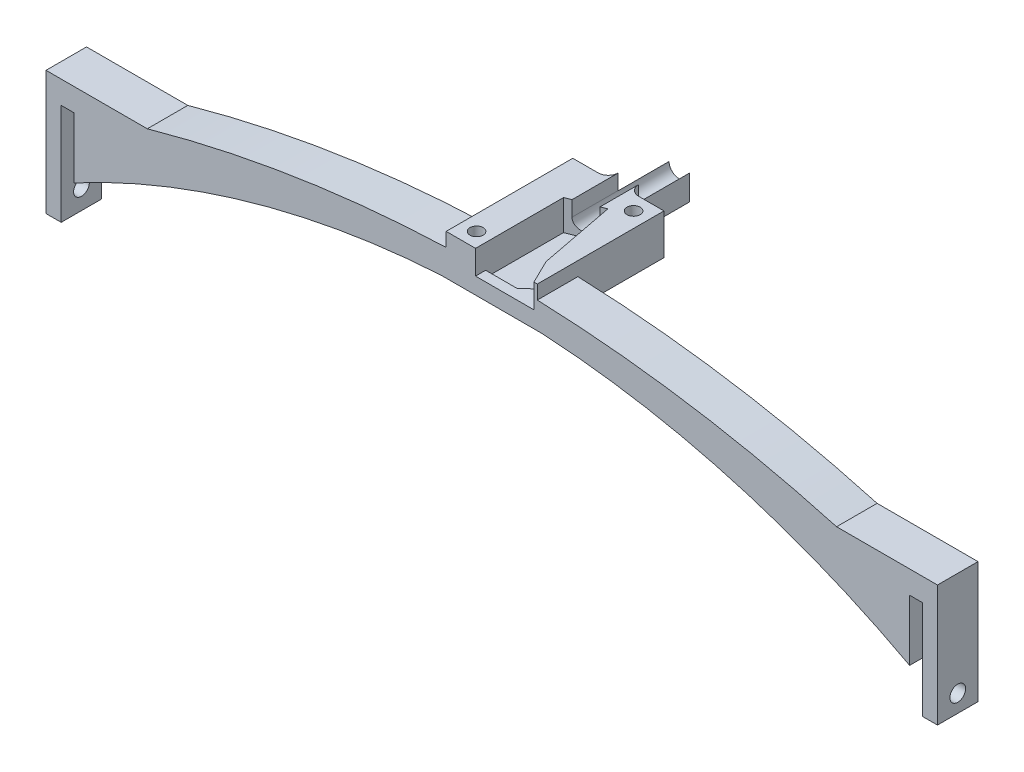
from build123d import *

# Parameters (mm, degrees)
BOSS_EXTRUDE1_DEPTH     = 8
SKETCH2_R               = 1.55
CUT_EXTRUDE1_DEPTH      = 177
BOSS_EXTRUDE3_START     = 20.459902
SKETCH3_R               = 1.3
BOSS_EXTRUDE3_DEPTH     = 8
CUT_EXTRUDE2_START      = -2
CUT_EXTRUDE2_DEPTH      = 40
SKETCH3_3_R             = 1.3
CUT_EXTRUDE3_DEPTH      = 29.4599021
CUT_EXTRUDE3_DEPTH_BACK = 9
CUT_EXTRUDE4_DEPTH      = 6
CUT_EXTRUDE5_DEPTH      = 4.75
FILLET1_R               = 2


with BuildPart() as part:
    # Sketch1 → Boss-Extrude1 (new body)
    with BuildSketch(Plane.XY):
        with BuildLine():
            Line((-3, 0), (-3, 16.5))
            Line((-3, 16.5), (17, 16.5))
            ThreePointArc((17, 16.5), (85.039654136, 25.877266165), (153.079308271, 16.5))
            Line((153.079308271, 16.5), (173, 16.5))
            Line((173, 16.5), (173, 0.544153422))
            Line((173, 0.544153422), (173, -7.455846578))
            Line((173, -7.455846578), (170, -7.455846578))
            Line((170, -7.455846578), (170, 0))
            Line((170, 0), (170.005951762, 12.036791894))
            Line((170.005951762, 12.036791894), (170, 12))
            Line((170, 12), (167.5, 12))
            Line((167.5, 12), (167.5, 0))
            ThreePointArc((167.5, 0), (132.367862473, 14.191115036), (95, 20.459901787))
            Line((95, 20.459901787), (75, 20.459901787))
            ThreePointArc((75, 20.459901787), (37.632137527, 14.191115036), (2.5, 0))
            Line((2.5, 0), (2.5, 12))
            Line((2.5, 12), (0, 12))
            Line((0, 12), (0, 0))
            Line((0, 0), (0, -8))
            Line((0, -8), (-3, -8))
            Line((-3, -8), (-3, 0))
        make_face()
    extrude(amount=BOSS_EXTRUDE1_DEPTH)

    # Sketch2 → Cut-Extrude1 (cut, through all)
    with BuildSketch(Plane.ZY.offset(3)):
        with Locations((4, -4)):
            Circle(SKETCH2_R)
    extrude(amount=-CUT_EXTRUDE1_DEPTH, mode=Mode.SUBTRACT)

    # Sketch3 → Boss-Extrude3 (add)
    with BuildSketch(Plane(origin=(0, 0, 0), x_dir=(1, 0, 0), z_dir=(0, 1, 0)).offset(BOSS_EXTRUDE3_START)):
        Polygon((94, 17), (87, 17), (87, 29), (83, 29), (83, 17), (76, 17), (76, -8), (94, -8), align=None)
        with Locations((91, 14)):
            Circle(SKETCH3_R, mode=Mode.SUBTRACT)
        with Locations((79, -5)):
            Circle(SKETCH3_R, mode=Mode.SUBTRACT)
    extrude(amount=BOSS_EXTRUDE3_DEPTH)

    # Sketch5 → Cut-Extrude2 (cut)
    with BuildSketch(Plane.XY.offset(8).offset(CUT_EXTRUDE2_START)):
        with BuildLine():
            Line((82.9995, 25.459901787), (82.9995, 28.459901787))
            Line((82.9995, 28.459901787), (87.0005, 28.459901787))
            Line((87.0005, 28.459901787), (87.0005, 25.459901787))
            ThreePointArc((87.0005, 25.459901787), (85, 23.459401787), (82.9995, 25.459901787))
        make_face()
    extrude(amount=-CUT_EXTRUDE2_DEPTH, mode=Mode.SUBTRACT)

    # Sketch3_3 → Cut-Extrude3 (cut, two sides)
    with BuildSketch(Plane(origin=(0, 0, 0), x_dir=(1, 0, 0), z_dir=(0, 1, 0))) as cut_extrude3_sk:
        with Locations((79, -5)):
            Circle(SKETCH3_3_R)
    extrude(amount=CUT_EXTRUDE3_DEPTH, mode=Mode.SUBTRACT)
    extrude(cut_extrude3_sk.sketch, amount=-CUT_EXTRUDE3_DEPTH_BACK, mode=Mode.SUBTRACT)

    # Sketch6 → Cut-Extrude4 (cut)
    with BuildSketch(Plane(origin=(0, 28.459901787, 0), x_dir=(1, 0, 0), z_dir=(0, 1, 0))):
        Polygon((81.7995, 9.38), (88.113465558, 11.808798865), (91.0245, -3.288104906), (87.9495, -6), (81.7995, -6), align=None)
    extrude(amount=-CUT_EXTRUDE4_DEPTH, mode=Mode.SUBTRACT)

    # Sketch7 → Cut-Extrude5 (cut)
    with BuildSketch(Plane(origin=(0, 28.459901787, 0), x_dir=(1, 0, 0), z_dir=(0, 1, 0))):
        Polygon((91.0245, -3.288104906), (93.328799585, -8), (81.7995, -8), (81.7995, -6), (87.9495, -6), align=None)
    extrude(amount=-CUT_EXTRUDE5_DEPTH, mode=Mode.SUBTRACT)

    # Fillet1
    fillet1_edges = [part.edges().sort_by_distance(p)[0] for p in [
        (87, 22.937539816, -17),
        (83, 22.937539816, -17),
    ]]
    fillet(fillet1_edges, radius=FILLET1_R)


solid = part.part
